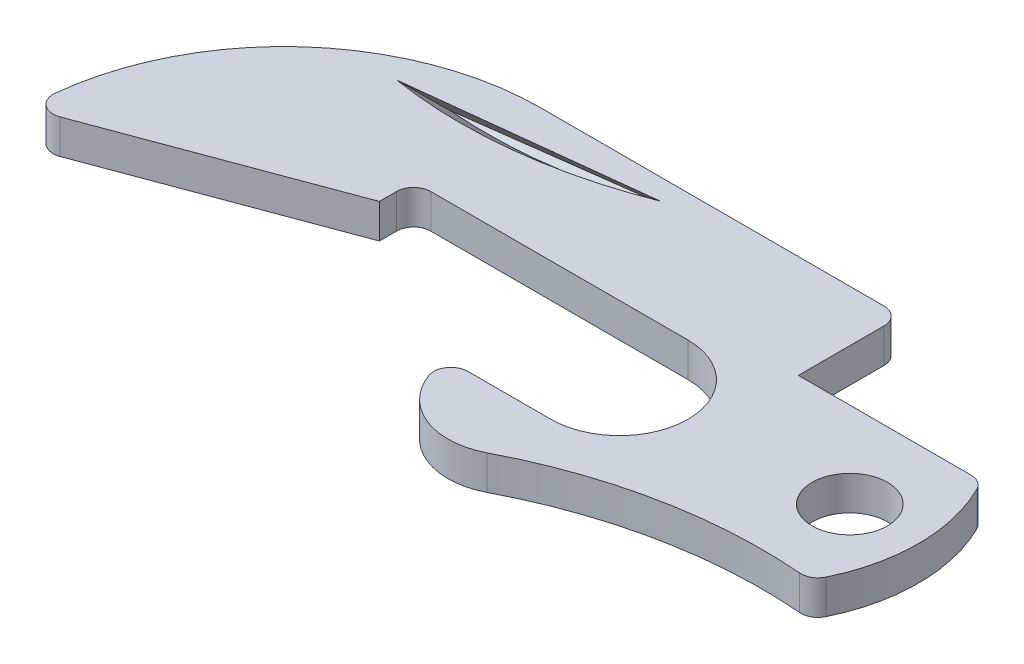
from build123d import *

# Parameters (mm, degrees)
SKETCH1_R           = 1.397
BOSS_EXTRUDE1_DEPTH = 1.27
FILLET1_R           = 0.635
CUT_EXTRUDE3_DEPTH  = 2.286
CUT_EXTRUDE3_DRAFT  = -5


with BuildPart() as part:
    # Sketch1 → Boss-Extrude1 (new body)
    with BuildSketch(Plane(origin=(0, 0, 0), x_dir=(1, 0, 0), z_dir=(0, 1, 0))):
        with BuildLine():
            Line((0, 0), (-6.769261314, 0))
            Line((-6.769261314, 0), (-6.769261314, 3.81))
            Line((-6.769261314, 3.81), (-20.104261314, 3.81))
            ThreePointArc((-20.104261314, 3.81), (-26.839453405, 1.020192091), (-29.629261314, -5.715))
            Line((-29.629261314, -5.715), (-20.104261314, -2.17946963))
            Line((-20.104261314, -2.17946963), (-20.104261314, -0.90946963))
            Line((-20.104261314, -0.90946963), (-9.944261314, -0.90946963))
            ThreePointArc((-9.944261314, -0.90946963), (-7.404261314, -3.44946963), (-9.944261314, -5.98946963))
            Line((-9.944261314, -5.98946963), (-13.754261314, -5.98946963))
            ThreePointArc((-13.754261314, -5.98946963), (-12.534056747, -8.159663173), (-10.045804609, -8.244754297))
            ThreePointArc((-10.045804609, -8.244754297), (-5.162016489, -6.559807155), (0, -6.35))
            ThreePointArc((0, -6.35), (0.850738686, -3.175), (0, 0))
        make_face()
        with Locations((-1.689261314, -3.175)):
            Circle(SKETCH1_R, mode=Mode.SUBTRACT)
    extrude(amount=BOSS_EXTRUDE1_DEPTH)

    # Fillet1
    fillet1_edges = [part.edges().sort_by_distance(p)[0] for p in [
        (0, 0.635, 6.35),
        (-13.754261314, 0.635, 5.98946963),
        (-20.104261314, 0.635, 0.90946963),
        (-29.629261314, 0.635, 5.715),
        (-6.769261314, 0.635, -3.81),
        (0, 0.635, 0),
    ]]
    fillet(fillet1_edges, radius=FILLET1_R)


with BuildPart() as cut_extrude3_tool:
    # Sketch3 → Cut-Extrude3 (with draft: the straight prism first)
    with BuildSketch(Plane(origin=(0, 0.454734815, 0.454734815), x_dir=(1, 0, 0), z_dir=(0, 0.707106781, 0.707106781))):
        with BuildLine():
            ThreePointArc((-24.669594842, 2.353522249), (-18.89739116, 2.199678883), (-13.239594842, 3.353517673))
            Line((-13.239594842, 3.353517673), (-24.669594842, 2.353522249))
        make_face()
    extrude(amount=-CUT_EXTRUDE3_DEPTH)
    # Cut-Extrude3: the draft: its side faces are tilted about the plane it starts from
    cut_extrude3_sides = [cut_extrude3_tool.faces().sort_by_distance(p)[0] for p in [
        (-18.89739116, 1.201919619, -1.908896091),
        (-18.954594842, 1.664255078, -2.371231551),
    ]]
    draft(cut_extrude3_sides, Plane(origin=(0, 0.454734815, 0.454734815), x_dir=(1, 0, 0), z_dir=(0, 0.707106781, 0.707106781)), CUT_EXTRUDE3_DRAFT)


with BuildPart() as part_1:
    add(part.part)

    # Cut-Extrude3: cut by cut_extrude3_tool
    add(cut_extrude3_tool.part, mode=Mode.SUBTRACT)


solid = part_1.part
